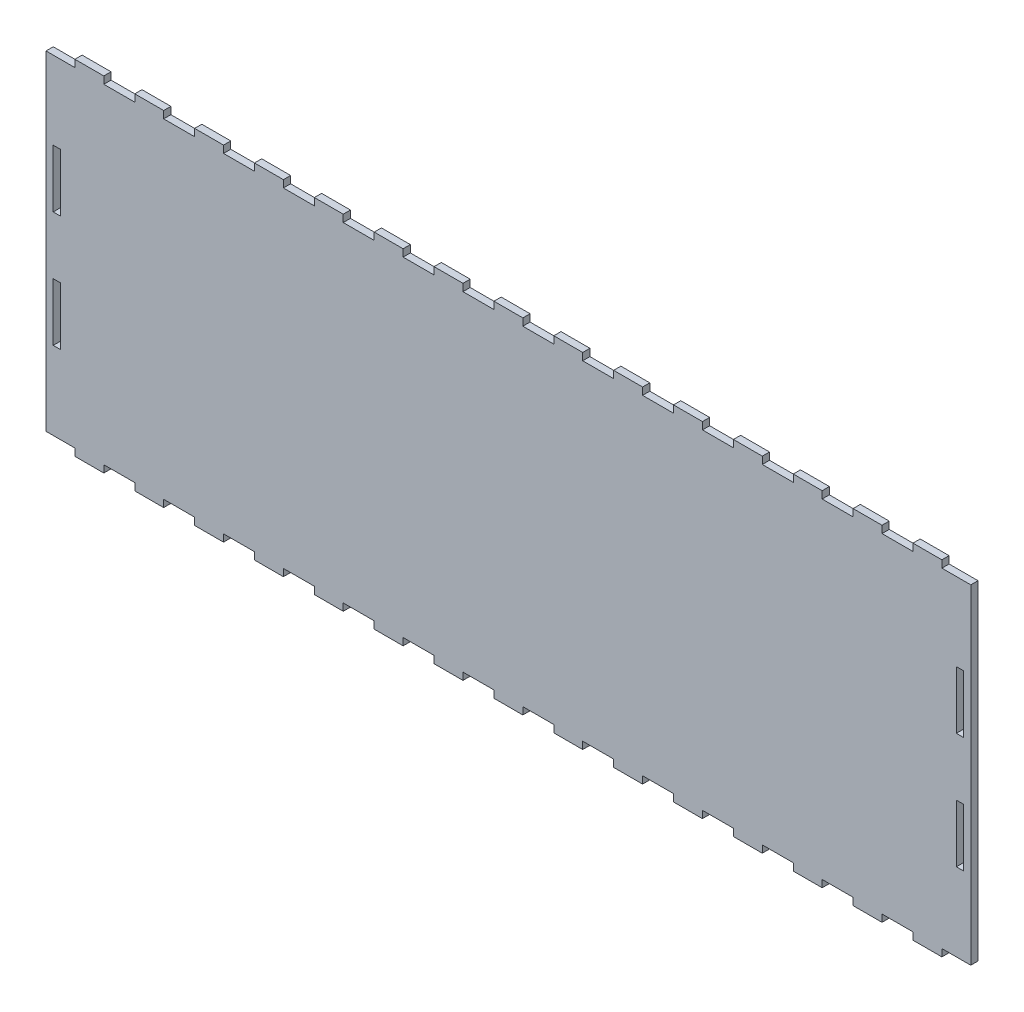
from build123d import *

# Parameters (mm, degrees)
SKETCH1_W           = 3.175
SKETCH1_H           = 25.4
BOSS_EXTRUDE1_DEPTH = 3.175


with BuildPart() as part:
    # Sketch1 → Boss-Extrude1 (new body)
    with BuildSketch(Plane.XY):
        Polygon((406.4, 0), (406.4, 144.78), (393.7, 144.78), (393.7, 147.955), (381, 147.955), (381, 144.78), (367.392857143, 144.78), (367.392857143, 147.955), (354.692857143, 147.955), (354.692857143, 144.78), (341.085714286, 144.78), (341.085714286, 147.955), (328.385714286, 147.955), (328.385714286, 144.78), (314.778571429, 144.78), (314.778571429, 147.955), (302.078571429, 147.955), (302.078571429, 144.78), (288.471428571, 144.78), (288.471428571, 147.955), (275.771428571, 147.955), (275.771428571, 144.78), (262.164285714, 144.78), (262.164285714, 147.955), (249.464285714, 147.955), (249.464285714, 144.78), (235.857142857, 144.78), (235.857142857, 147.955), (223.157142857, 147.955), (223.157142857, 144.78), (209.55, 144.78), (209.55, 147.955), (196.85, 147.955), (196.85, 144.78), (183.242857143, 144.78), (183.242857143, 147.955), (170.542857143, 147.955), (170.542857143, 144.78), (156.935714286, 144.78), (156.935714286, 147.955), (144.235714286, 147.955), (144.235714286, 144.78), (130.628571429, 144.78), (130.628571429, 147.955), (117.928571429, 147.955), (117.928571429, 144.78), (104.321428571, 144.78), (104.321428571, 147.955), (91.621428571, 147.955), (91.621428571, 144.78), (78.014285714, 144.78), (78.014285714, 147.955), (65.314285714, 147.955), (65.314285714, 144.78), (51.707142857, 144.78), (51.707142857, 147.955), (39.007142857, 147.955), (39.007142857, 144.78), (25.4, 144.78), (25.4, 147.955), (12.7, 147.955), (12.7, 144.78), (0, 144.78), (0, 0), (12.7, 0), (12.7, -3.175), (25.4, -3.175), (25.4, 0), (39.007142857, 0), (39.007142857, -3.175), (51.707142857, -3.175), (51.707142857, 0), (65.314285714, 0), (65.314285714, -3.175), (78.014285714, -3.175), (78.014285714, 0), (91.621428571, 0), (91.621428571, -3.175), (104.321428571, -3.175), (104.321428571, 0), (117.928571429, 0), (117.928571429, -3.175), (130.628571429, -3.175), (130.628571429, 0), (144.235714286, 0), (144.235714286, -3.175), (156.935714286, -3.175), (156.935714286, 0), (170.542857143, 0), (170.542857143, -3.175), (183.242857143, -3.175), (183.242857143, 0), (196.85, 0), (196.85, -3.175), (209.55, -3.175), (209.55, 0), (223.157142857, 0), (223.157142857, -3.175), (235.857142857, -3.175), (235.857142857, 0), (249.464285714, 0), (249.464285714, -3.175), (262.164285714, -3.175), (262.164285714, 0), (275.771428571, 0), (275.771428571, -3.175), (288.471428571, -3.175), (288.471428571, 0), (302.078571429, 0), (302.078571429, -3.175), (314.778571429, -3.175), (314.778571429, 0), (328.385714286, 0), (328.385714286, -3.175), (341.085714286, -3.175), (341.085714286, 0), (354.692857143, 0), (354.692857143, -3.175), (367.392857143, -3.175), (367.392857143, 0), (381, 0), (381, -3.175), (393.7, -3.175), (393.7, 0), align=None)
        with Locations((401.6375, 97.79)):
            Rectangle(SKETCH1_W, SKETCH1_H, mode=Mode.SUBTRACT)
        with Locations((4.7625, 46.99)):
            Rectangle(SKETCH1_W, SKETCH1_H, mode=Mode.SUBTRACT)
        with Locations((4.7625, 97.79)):
            Rectangle(SKETCH1_W, SKETCH1_H, mode=Mode.SUBTRACT)
        with Locations((401.6375, 46.99)):
            Rectangle(SKETCH1_W, SKETCH1_H, mode=Mode.SUBTRACT)
    extrude(amount=BOSS_EXTRUDE1_DEPTH)


solid = part.part
